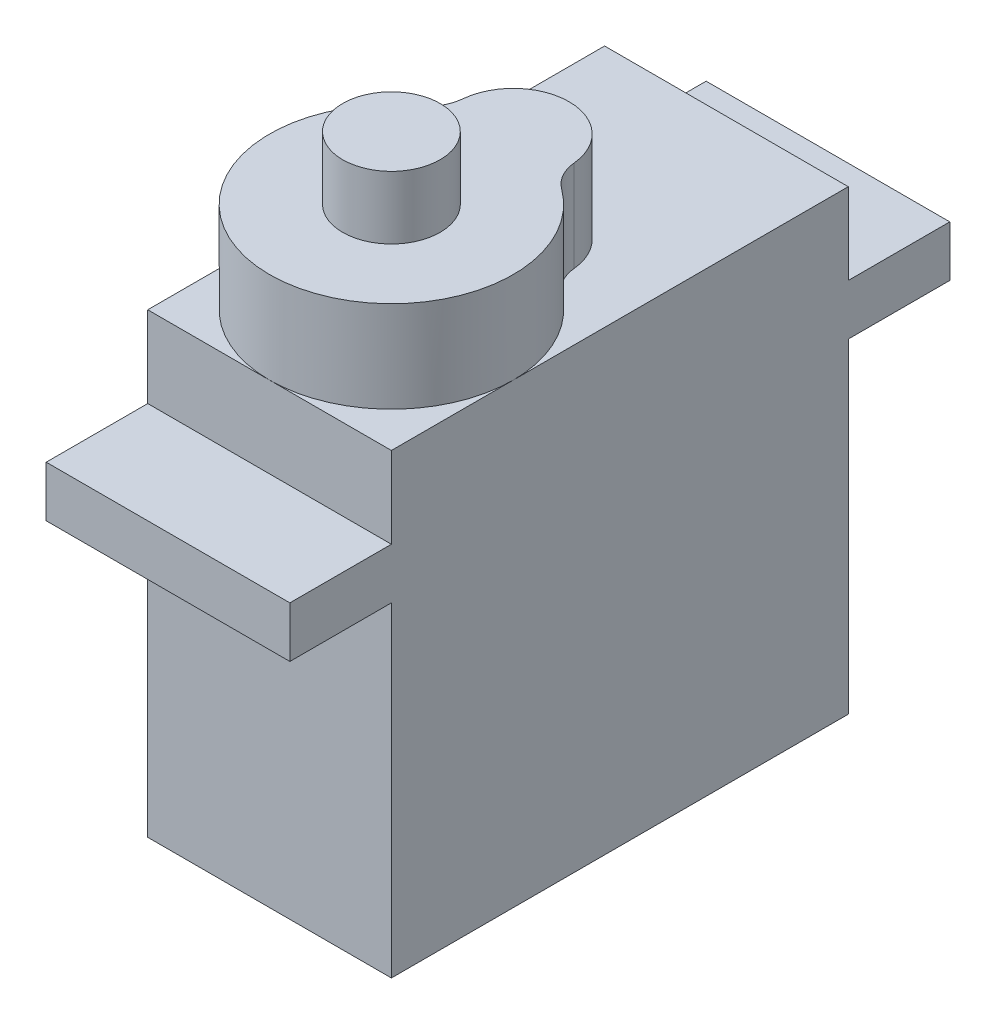
from build123d import *

# Parameters (mm, degrees)
CROQUIS1_W              = 12
CROQUIS1_H              = 22.5
SALIENTE_EXTRUIR1_DEPTH = 22.5
CROQUIS2_W              = 5
CROQUIS2_H              = 2.5
SALIENTE_EXTRUIR2_DEPTH = 12
CROQUIS3_R              = 6
SALIENTE_EXTRUIR3_DEPTH = 4.5
CROQUIS4_R              = 2.4
SALIENTE_EXTRUIR4_DEPTH = 3.1
CROQUIS5_R              = 2.75
SALIENTE_EXTRUIR5_DEPTH = 4.5
REDONDEO1_R             = 2


with BuildPart() as part:
    # Croquis1 → Saliente-Extruir1 (new body)
    with BuildSketch(Plane(origin=(0, 0, 0), x_dir=(1, 0, 0), z_dir=(0, 1, 0))):
        Rectangle(CROQUIS1_W, CROQUIS1_H)
    extrude(amount=SALIENTE_EXTRUIR1_DEPTH)

    # Croquis2 → Saliente-Extruir2 (add)
    with BuildSketch(Plane(origin=(6, 0, 0), x_dir=(0, 0, -1), z_dir=(1, 0, 0))):
        with Locations((-13.75, 17.25)):
            Rectangle(CROQUIS2_W, CROQUIS2_H)
        with Locations((13.75, 17.25)):
            Rectangle(CROQUIS2_W, CROQUIS2_H)
    extrude(amount=-SALIENTE_EXTRUIR2_DEPTH)

    # Croquis3 → Saliente-Extruir3 (add)
    with BuildSketch(Plane(origin=(0, 22.5, 0), x_dir=(1, 0, 0), z_dir=(0, 1, 0))):
        with Locations((0, -5.25)):
            Circle(CROQUIS3_R)
    extrude(amount=SALIENTE_EXTRUIR3_DEPTH)

    # Croquis4 → Saliente-Extruir4 (add)
    with BuildSketch(Plane(origin=(0, 27, 0), x_dir=(1, 0, 0), z_dir=(0, 1, 0))):
        with Locations((0, -5.25)):
            Circle(CROQUIS4_R)
    extrude(amount=SALIENTE_EXTRUIR4_DEPTH)

    # Croquis5 → Saliente-Extruir5 (add)
    with BuildSketch(Plane(origin=(0, 22.5, 0), x_dir=(1, 0, 0), z_dir=(0, 1, 0))):
        with Locations((0, 0.75)):
            Circle(CROQUIS5_R)
    extrude(amount=SALIENTE_EXTRUIR5_DEPTH)

    # Redondeo1
    redondeo1_edges = [part.edges().sort_by_distance(p)[0] for p in [
        (2.676814797, 24.75, -0.119791667),
        (-2.676814797, 24.75, -0.119791667),
    ]]
    fillet(redondeo1_edges, radius=REDONDEO1_R)


solid = part.part
